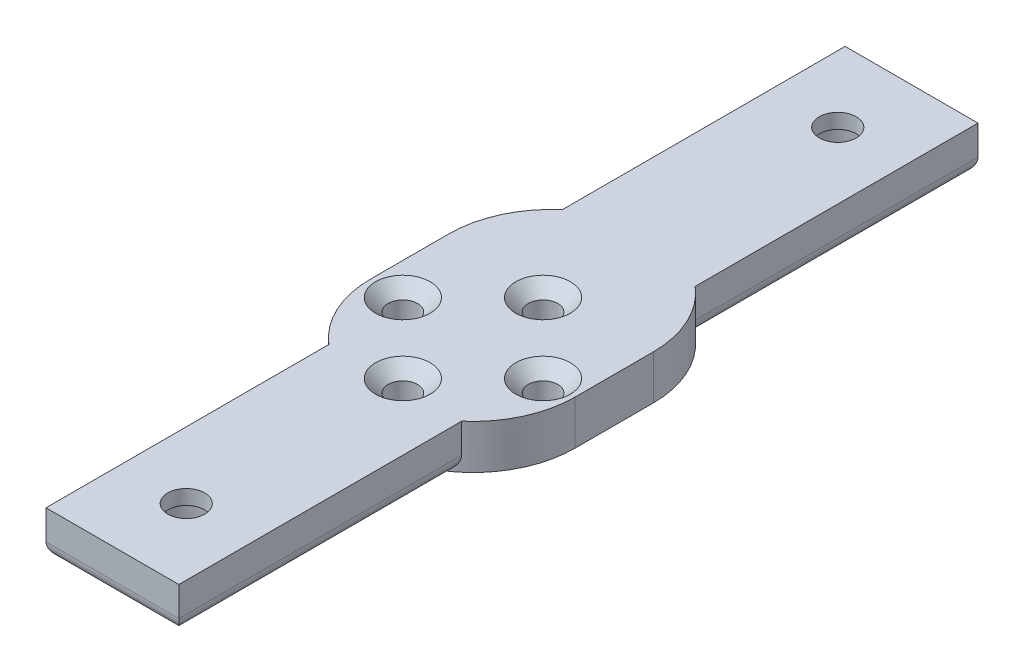
from build123d import *

# Parameters (mm, degrees)
BOSS_EXTRUDE1_DEPTH = 6
SKETCH4_R           = 2.5
SKETCH4_R_2         = 2
CUT_EXTRUDE1_DEPTH  = 6
CHAMFER1_SIZE       = 1.7
FILLET1_R           = 2
SKETCH5_R           = 4.25
CUT_EXTRUDE2_DEPTH  = 4


with BuildPart() as part:
    # Sketch1 → Boss-Extrude1 (new body)
    with BuildSketch(Plane(origin=(0, 0, 0), x_dir=(1, 0, 0), z_dir=(0, 1, 0))):
        with BuildLine():
            Line((-13.85, 5.29), (-13.85, -5.29))
            ThreePointArc((-13.85, -5.29), (-12.5791991, -11.085364527), (-9, -15.817226605))
            Line((-9, -15.817226605), (-9, -54.14))
            Line((-9, -54.14), (9, -54.14))
            Line((9, -54.14), (9, -15.817226605))
            ThreePointArc((9, -15.817226605), (12.5791991, -11.085364527), (13.85, -5.29))
            Line((13.85, -5.29), (13.85, 5.29))
            ThreePointArc((13.85, 5.29), (12.5791991, 11.085364527), (9, 15.817226605))
            Line((9, 15.817226605), (9, 54.14))
            Line((9, 54.14), (-9, 54.14))
            Line((-9, 54.14), (-9, 15.817226605))
            ThreePointArc((-9, 15.817226605), (-12.5791991, 11.085364527), (-13.85, 5.29))
        make_face()
    extrude(amount=BOSS_EXTRUDE1_DEPTH)

    # Sketch4 → Cut-Extrude1 (cut)
    with BuildSketch(Plane(origin=(0, 6, 0), x_dir=(1, 0, 0), z_dir=(0, 1, 0))):
        with Locations((0, 44.14)):
            Circle(SKETCH4_R)
        with Locations((0, -44.14)):
            Circle(SKETCH4_R)
        with Locations((-9.5, -5.29)):
            Circle(SKETCH4_R_2)
        with Locations((9.5, -5.29)):
            Circle(SKETCH4_R_2)
        with Locations((0, 4.21)):
            Circle(SKETCH4_R_2)
        with Locations((0, -14.79)):
            Circle(SKETCH4_R_2)
    extrude(amount=-CUT_EXTRUDE1_DEPTH, mode=Mode.SUBTRACT)

    # Chamfer1
    chamfer1_edges = [part.edges().sort_by_distance(p)[0] for p in [
        (-2, 6, 14.79),
        (-11.5, 6, 5.29),
        (7.5, 6, 5.29),
        (-2, 6, -4.21),
    ]]
    chamfer(chamfer1_edges, length=CHAMFER1_SIZE)

    # Fillet1
    fillet1_edges = [part.edges().sort_by_distance(p)[0] for p in [
        (9, 0, 34.978613303),
        (0, 0, 54.14),
        (-9, 0, 34.978613303),
        (-9, 0, -34.978613303),
        (0, 0, -54.14),
        (9, 0, -34.978613303),
    ]]
    fillet(fillet1_edges, radius=FILLET1_R)

    # Sketch5 → Cut-Extrude2 (cut)
    with BuildSketch(Plane.XZ):
        with Locations((0, -44.14)):
            Circle(SKETCH5_R)
        with Locations((0, 44.14)):
            Circle(SKETCH5_R)
    extrude(amount=-CUT_EXTRUDE2_DEPTH, mode=Mode.SUBTRACT)


solid = part.part
